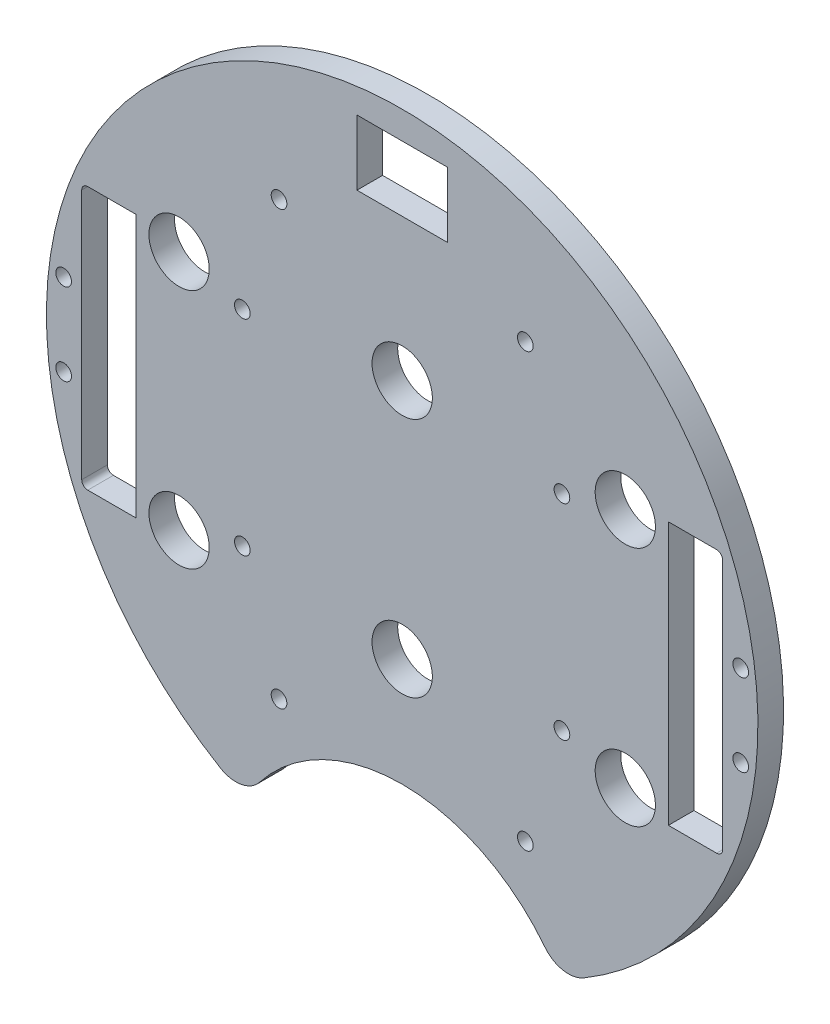
from build123d import *

# Parameters (mm, degrees)
BOSS_EXTRUDE2_DEPTH      = 5.3975
SKETCH2_W                = 19.05
SKETCH2_H                = 13.716
CUT_EXTRUDE1_DEPTH       = 107.104395791
SKETCH3_R                = 38.1
CUT_EXTRUDE2_DEPTH       = 107.104395791
FILLET1_R                = 6.35
SKETCH8_R                = 1.651
CUT_EXTRUDE7_DEPTH       = 75.692
SKETCH10_R               = 1.651
CUT_EXTRUDE9_DEPTH       = 97.79
SKETCH11_R               = 1.651
CUT_EXTRUDE10_DEPTH      = 150.876
SKETCH12_R               = 3.175
CUT_EXTRUDE11_DEPTH      = 103.378
CUT_EXTRUDE11_DEPTH_BACK = 48.768
SKETCH13_R               = 6.35
CUT_EXTRUDE12_DEPTH      = 26.416


with BuildPart() as part:
    # Sketch1 → Boss-Extrude2 (new body)
    with BuildSketch(Plane.XY):
        with BuildLine():
            ThreePointArc((-69.525975721, 27.94), (-74.93, 0), (-69.525975721, -27.94))
            ThreePointArc((-69.525975721, -27.94), (0, -74.93), (69.525975721, -27.94))
            ThreePointArc((69.525975721, -27.94), (73.56658977, -14.228906128), (74.93, 0))
            ThreePointArc((74.93, 0), (73.56658977, 14.228906128), (69.525975721, 27.94))
            ThreePointArc((69.525975721, 27.94), (0, 74.93), (-69.525975721, 27.94))
        make_face()
        with BuildLine():
            ThreePointArc((-67.493975721, 26.416), (-67.122001333, 27.314025612), (-66.223975721, 27.686))
            Line((-66.223975721, 27.686), (-56.063975721, 27.686))
            Line((-56.063975721, 27.686), (-56.063975721, -27.686))
            Line((-56.063975721, -27.686), (-66.223975721, -27.686))
            ThreePointArc((-66.223975721, -27.686), (-67.122001333, -27.314025612), (-67.493975721, -26.416))
            Line((-67.493975721, -26.416), (-67.493975721, 26.416))
        make_face(mode=Mode.SUBTRACT)
        with BuildLine():
            ThreePointArc((66.223975721, 27.686), (67.122001333, 27.314025612), (67.493975721, 26.416))
            Line((67.493975721, 26.416), (67.493975721, -26.416))
            ThreePointArc((67.493975721, -26.416), (67.122001333, -27.314025612), (66.223975721, -27.686))
            Line((66.223975721, -27.686), (56.063975721, -27.686))
            Line((56.063975721, -27.686), (56.063975721, 27.686))
            Line((56.063975721, 27.686), (66.223975721, 27.686))
        make_face(mode=Mode.SUBTRACT)
    extrude(amount=BOSS_EXTRUDE2_DEPTH)

    # Sketch2 → Cut-Extrude1 (cut, through all)
    with BuildSketch(Plane.XY.offset(5.3975)):
        with Locations((0, 62.23)):
            Rectangle(SKETCH2_W, SKETCH2_H)
    extrude(amount=-CUT_EXTRUDE1_DEPTH, mode=Mode.SUBTRACT)

    # Sketch3 → Cut-Extrude2 (cut, through all)
    with BuildSketch(Plane.XY.offset(5.3975)):
        with Locations((0, -86.312058398)):
            Circle(SKETCH3_R)
    extrude(amount=-CUT_EXTRUDE2_DEPTH, mode=Mode.SUBTRACT)

    # Fillet1
    fillet1_edges = [part.edges().sort_by_distance(p)[0] for p in [
        (-33.000960548, -67.271401821, 2.69875),
        (33.000960548, -67.271401821, 2.69875),
    ]]
    fillet(fillet1_edges, radius=FILLET1_R)

    # Sketch8 → Cut-Extrude7 (cut)
    with BuildSketch(Plane(origin=(30.092005081, 4.08352975, -11.4935), x_dir=(-1, 0, 0), z_dir=(0, 0, -1))):
        with Locations(Location((63.757223581, 17.50647025, 0), (0, 0, 180))):
            Circle(SKETCH8_R)
        with Locations(Location((63.757223581, -25.67352975, 0), (0, 0, 180))):
            Circle(SKETCH8_R)
        with Locations(Location((-3.552776419, -25.67352975, 0), (0, 0, 180))):
            Circle(SKETCH8_R)
        with Locations(Location((-3.552776419, 17.50647025, 0), (0, 0, 180))):
            Circle(SKETCH8_R)
    extrude(amount=-CUT_EXTRUDE7_DEPTH, mode=Mode.SUBTRACT)

    # Sketch10 → Cut-Extrude9 (cut)
    with BuildSketch(Plane(origin=(30.092005081, 4.08352975, -41.529), x_dir=(-1, 0, 0), z_dir=(0, 0, -1))):
        with Locations(Location((4.154396091, -49.728759131, 0), (0, 0, 180))):
            Circle(SKETCH10_R)
        with Locations(Location((56.02961407, -49.728759131, 0), (0, 0, 180))):
            Circle(SKETCH10_R)
        with Locations(Location((4.154396091, 41.38247025, 0), (0, 0, 180))):
            Circle(SKETCH10_R)
        with Locations(Location((56.02961407, 41.38247025, 0), (0, 0, 180))):
            Circle(SKETCH10_R)
    extrude(amount=-CUT_EXTRUDE9_DEPTH, mode=Mode.SUBTRACT)

    # Sketch11 → Cut-Extrude10 (cut)
    with BuildSketch(Plane(origin=(30.092005081, 4.08352975, 5.3975), x_dir=(1, 0, 0), z_dir=(0, 0, 1))):
        with Locations((-101.395980802, -12.71952975)):
            Circle(SKETCH11_R)
        with Locations((-101.395980802, 4.55247025)):
            Circle(SKETCH11_R)
        with Locations((41.211970641, -12.71952975)):
            Circle(SKETCH11_R)
        with Locations((41.211970641, 4.55247025)):
            Circle(SKETCH11_R)
    extrude(amount=-CUT_EXTRUDE10_DEPTH, mode=Mode.SUBTRACT)

    # Sketch12 → Cut-Extrude11 (cut, two sides)
    with BuildSketch(Plane(origin=(30.092005081, 4.08352975, -5.3975), x_dir=(-1, 0, 0), z_dir=(0, 0, -1))) as cut_extrude11_sk:
        with Locations(Location((-16.897994919, 21.31647025, 0), (0, 0, 180))):
            Circle(SKETCH12_R)
        with Locations(Location((77.082005081, 21.31647025, 0), (0, 0, 180))):
            Circle(SKETCH12_R)
        with Locations(Location((30.092005081, 21.31647025, 0), (0, 0, 180))):
            Circle(SKETCH12_R)
        with Locations(Location((77.082005081, -29.48352975, 0), (0, 0, 180))):
            Circle(SKETCH12_R)
        with Locations(Location((30.092005081, -29.48352975, 0), (0, 0, 180))):
            Circle(SKETCH12_R)
        with Locations(Location((-16.897994919, -29.48352975, 0), (0, 0, 180))):
            Circle(SKETCH12_R)
    extrude(amount=CUT_EXTRUDE11_DEPTH, mode=Mode.SUBTRACT)
    extrude(cut_extrude11_sk.sketch, amount=-CUT_EXTRUDE11_DEPTH_BACK, mode=Mode.SUBTRACT)

    # Sketch13 → Cut-Extrude12 (cut)
    with BuildSketch(Plane(origin=(0, 0, 0), x_dir=(-1, 0, 0), z_dir=(0, 0, -1))):
        with Locations((46.99, 25.4)):
            Circle(SKETCH13_R)
        with Locations((0, 25.4)):
            Circle(SKETCH13_R)
        with Locations((-46.99, 25.4)):
            Circle(SKETCH13_R)
        with Locations((-46.99, -25.4)):
            Circle(SKETCH13_R)
        with Locations((0, -25.4)):
            Circle(SKETCH13_R)
        with Locations((46.99, -25.4)):
            Circle(SKETCH13_R)
    extrude(amount=-CUT_EXTRUDE12_DEPTH, mode=Mode.SUBTRACT)


solid = part.part
